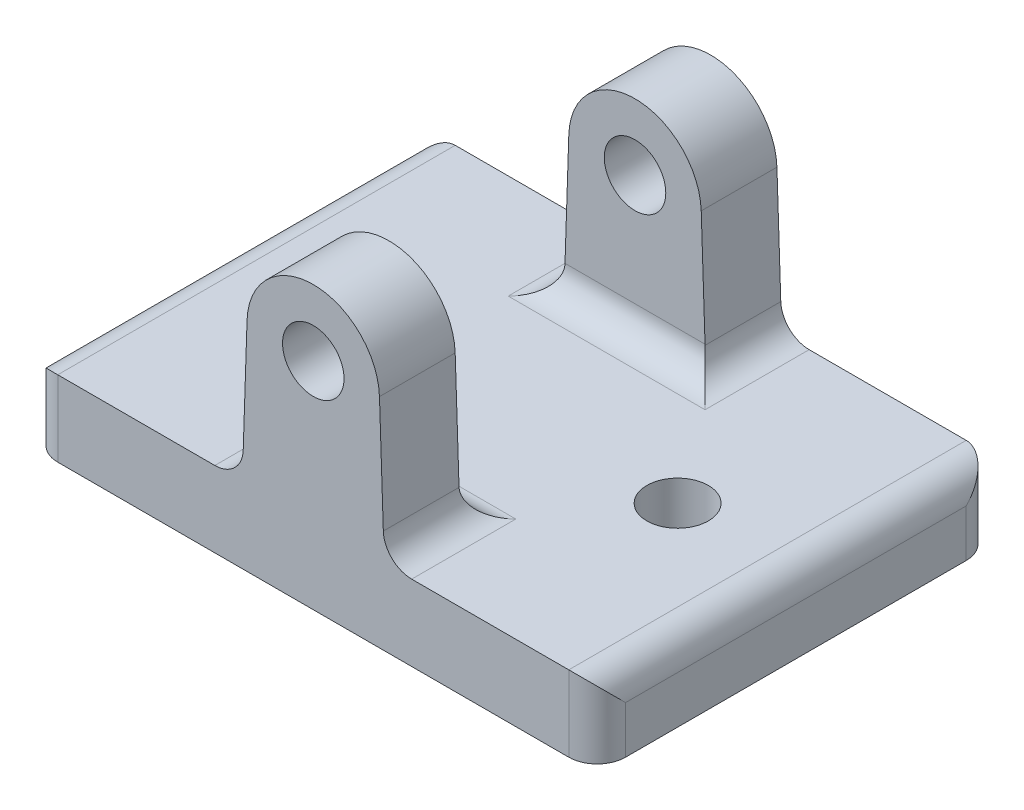
from build123d import *

# Parameters (mm, degrees)
SKETCH2_W           = 60
SKETCH2_H           = 42
SKETCH2_R           = 3.25
BOSS_EXTRUDE1_DEPTH = 8
SKETCH3_R           = 3.25
BOSS_EXTRUDE2_DEPTH = 8
FILLET1_R           = 3


with BuildPart() as part:
    # Sketch2 → Boss-Extrude1 (new body)
    with BuildSketch(Plane(origin=(0, 0, 0), x_dir=(1, 0, 0), z_dir=(0, 1, 0))):
        Rectangle(SKETCH2_W, SKETCH2_H)
        with Locations((-17.5, 0)):
            Circle(SKETCH2_R, mode=Mode.SUBTRACT)
        with Locations((17.5, 0)):
            Circle(SKETCH2_R, mode=Mode.SUBTRACT)
    extrude(amount=BOSS_EXTRUDE1_DEPTH)

    # Sketch3 → Boss-Extrude2 (add)
    with BuildSketch(Plane.XY.offset(21)):
        with BuildLine():
            Line((-7.5, 8), (-6.996052809, 23))
            ThreePointArc((-6.996052809, 23), (0, 29.764957256), (6.996052809, 23))
            Line((6.996052809, 23), (7.5, 8))
            Line((7.5, 8), (-7.5, 8))
        make_face()
        with Locations((0, 22.764957256)):
            Circle(SKETCH3_R, mode=Mode.SUBTRACT)
    boss_extrude2 = extrude(amount=-BOSS_EXTRUDE2_DEPTH)

    # Mirror1: Boss-Extrude2 across plane
    add(boss_extrude2.mirror(Plane.XY))

    # Fillet1
    fillet1_edges = [part.edges().sort_by_distance(p)[0] for p in [
        (-30, 8, 0),
        (0, 8, 13),
        (7.5, 8, 17),
        (-7.5, 8, 17),
        (0, 8, -13),
        (-7.5, 8, -17),
        (7.5, 8, -17),
        (30, 8, 0),
        (30, 4, 21),
        (-30, 4, 21),
        (-30, 4, -21),
        (30, 4, -21),
    ]]
    fillet(fillet1_edges, radius=FILLET1_R)


solid = part.part
